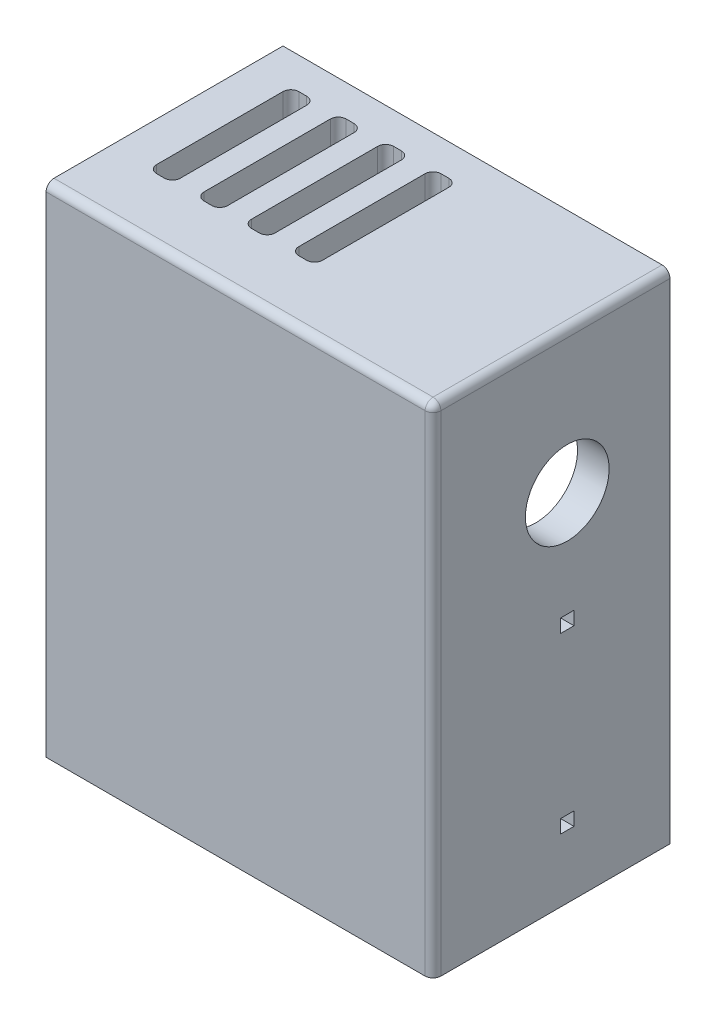
from build123d import *

# Parameters (mm, degrees)
SKETCH_1_W          = 49
SKETCH_1_H          = 63
EXTRUDE_1_DEPTH     = 4
SKETCH_2_W          = 45
SKETCH_2_H          = 4
SKETCH_2_W_2        = 4
SKETCH_2_H_2        = 59
EXTRUDE_2_DEPTH     = 26
SKETCH_3_W          = 14
SKETCH_3_H          = 8
SKETCH_3_W_2        = 30
EXTRUDE_3_DEPTH     = 7.2
SKETCH_5_R          = 5.3
CUT_EXTRUDE_1_DEPTH = 4
SKETCH_7_W          = 1.7
SKETCH_7_H          = 1.7
CUT_EXTRUDE_3_DEPTH = 6
SKETCH_8_W          = 1.7
SKETCH_8_H          = 1.7
CUT_EXTRUDE_4_DEPTH = 6
SKETCH_9_W          = 1.7
SKETCH_9_H          = 1.7
CUT_EXTRUDE_5_DEPTH = 6
FILLET_1_R          = 1
SKETCH_6_W          = 1.7
SKETCH_6_H          = 1.7
CUT_EXTRUDE_7_DEPTH = 5
SKETCH_10_W         = 15
SKETCH_10_H         = 27.7
EXTRUDE_4_DEPTH     = 2
CUT_EXTRUDE_8_DEPTH = 13
SKETCH_12_W         = 1.7
SKETCH_12_H         = 1.7
CUT_EXTRUDE_9_DEPTH = 5


with BuildPart() as part:
    # Эскиз1 → Бобышка-Вытянуть1 (new body)
    with BuildSketch(Plane.XY):
        with Locations((2.204545455, -4.295454545)):
            Rectangle(SKETCH_1_W, SKETCH_1_H)
    extrude(amount=EXTRUDE_1_DEPTH)

    # Эскиз2 → Бобышка-Вытянуть2 (add)
    with BuildSketch(Plane(origin=(0, 0, 0), x_dir=(-1, 0, 0), z_dir=(0, 0, -1))):
        with Locations((-0.204545455, 25.204545455)):
            Rectangle(SKETCH_2_W, SKETCH_2_H)
        with Locations((-24.704545455, -6.295454545)):
            Rectangle(SKETCH_2_W_2, SKETCH_2_H_2)
        with Locations((-24.704545455, 25.204545455)):
            Rectangle(SKETCH_2_W_2, SKETCH_2_H)
    extrude(amount=EXTRUDE_2_DEPTH)

    # Эскиз3 → Бобышка-Вытянуть3 (add)
    with BuildSketch(Plane(origin=(0, 0, 0), x_dir=(-1, 0, 0), z_dir=(0, 0, -1))):
        with Locations((-15.704545455, 19.204545455)):
            Rectangle(SKETCH_3_W, SKETCH_3_H)
        with Locations((-7.704545455, -23.795454545)):
            Rectangle(SKETCH_3_W_2, SKETCH_3_H)
    extrude(amount=EXTRUDE_3_DEPTH)

    # Эскиз5 → Вырез-Вытянуть1 (cut)
    with BuildSketch(Plane.ZY.offset(-22.704545455)):
        with Locations((-13, 9.204545455)):
            Circle(SKETCH_5_R)
    extrude(amount=-CUT_EXTRUDE_1_DEPTH, mode=Mode.SUBTRACT)

    # Эскиз7 → Вырез-Вытянуть3 (cut)
    with BuildSketch(Plane.ZY.offset(22.295454545)):
        with Locations((1.75, 24.954545455)):
            Rectangle(SKETCH_7_W, SKETCH_7_H)
    extrude(amount=-CUT_EXTRUDE_3_DEPTH, mode=Mode.SUBTRACT)

    # Эскиз8 → Вырез-Вытянуть4 (cut)
    with BuildSketch(Plane.XZ.offset(35.795454545)):
        with Locations((24.454545455, 1.75)):
            Rectangle(SKETCH_8_W, SKETCH_8_H)
    extrude(amount=-CUT_EXTRUDE_4_DEPTH, mode=Mode.SUBTRACT)

    # Эскиз9 → Вырез-Вытянуть5 (cut)
    with BuildSketch(Plane(origin=(0, 0, -26), x_dir=(-1, 0, 0), z_dir=(0, 0, -1))):
        with Locations((-24.454545455, 24.954545455)):
            Rectangle(SKETCH_9_W, SKETCH_9_H)
    extrude(amount=-CUT_EXTRUDE_5_DEPTH, mode=Mode.SUBTRACT)

    # Скругление1
    fillet_1_edges = [part.edges().sort_by_distance(p)[0] for p in [
        (26.704545455, -4.295454545, 4),
        (2.204545455, 27.204545455, 4),
        (26.704545455, 27.204545455, -11),
    ]]
    fillet(fillet_1_edges, radius=FILLET_1_R)

    # Эскиз6 → Вырез-Вытянуть7 (cut)
    with BuildSketch(Plane(origin=(26.704545455, 0, 0), x_dir=(0, 0, -1), z_dir=(1, 0, 0))):
        with Locations((13, -4.945454545)):
            Rectangle(SKETCH_6_W, SKETCH_6_H)
        with Locations((13, -26.945454545)):
            Rectangle(SKETCH_6_W, SKETCH_6_H)
    extrude(amount=-CUT_EXTRUDE_7_DEPTH, mode=Mode.SUBTRACT)

    # Эскиз10 → Бобышка-Вытянуть4 (add)
    with BuildSketch(Plane.ZY.offset(-22.704545455)):
        with Locations((-7.5, -15.945454545)):
            Rectangle(SKETCH_10_W, SKETCH_10_H)
    extrude(amount=EXTRUDE_4_DEPTH)

    # Эскиз11 → Вырез-Вытянуть8 (cut)
    with BuildSketch(Plane(origin=(0, 27.204545455, 0), x_dir=(1, 0, 0), z_dir=(0, 1, 0))):
        with BuildLine():
            Line((2.704545455, 4), (1.704545455, 4))
            ThreePointArc((1.704545455, 4), (0.997438673, 4.292893219), (0.704545455, 5))
            Line((0.704545455, 5), (0.704545455, 21))
            ThreePointArc((0.704545455, 21), (0.997438673, 21.707106781), (1.704545455, 22))
            Line((1.704545455, 22), (2.704545455, 22))
            ThreePointArc((2.704545455, 22), (3.411652236, 21.707106781), (3.704545455, 21))
            Line((3.704545455, 21), (3.704545455, 5))
            ThreePointArc((3.704545455, 5), (3.411652236, 4.292893219), (2.704545455, 4))
        make_face()
        with BuildLine():
            Line((-3.295454545, 4), (-4.295454545, 4))
            ThreePointArc((-4.295454545, 4), (-5.002561327, 4.292893219), (-5.295454545, 5))
            Line((-5.295454545, 5), (-5.295454545, 21))
            ThreePointArc((-5.295454545, 21), (-5.002561327, 21.707106781), (-4.295454545, 22))
            Line((-4.295454545, 22), (-3.295454545, 22))
            ThreePointArc((-3.295454545, 22), (-2.588347764, 21.707106781), (-2.295454545, 21))
            Line((-2.295454545, 21), (-2.295454545, 5))
            ThreePointArc((-2.295454545, 5), (-2.588347764, 4.292893219), (-3.295454545, 4))
        make_face()
        with BuildLine():
            Line((-9.295454545, 4), (-10.295454545, 4))
            ThreePointArc((-10.295454545, 4), (-11.002561327, 4.292893219), (-11.295454545, 5))
            Line((-11.295454545, 5), (-11.295454545, 21))
            ThreePointArc((-11.295454545, 21), (-11.002561327, 21.707106781), (-10.295454545, 22))
            Line((-10.295454545, 22), (-9.295454545, 22))
            ThreePointArc((-9.295454545, 22), (-8.588347764, 21.707106781), (-8.295454545, 21))
            Line((-8.295454545, 21), (-8.295454545, 5))
            ThreePointArc((-8.295454545, 5), (-8.588347764, 4.292893219), (-9.295454545, 4))
        make_face()
        with BuildLine():
            Line((-15.295454545, 4), (-16.295454545, 4))
            ThreePointArc((-16.295454545, 4), (-17.002561327, 4.292893219), (-17.295454545, 5))
            Line((-17.295454545, 5), (-17.295454545, 21))
            ThreePointArc((-17.295454545, 21), (-17.002561327, 21.707106781), (-16.295454545, 22))
            Line((-16.295454545, 22), (-15.295454545, 22))
            ThreePointArc((-15.295454545, 22), (-14.588347764, 21.707106781), (-14.295454545, 21))
            Line((-14.295454545, 21), (-14.295454545, 5))
            ThreePointArc((-14.295454545, 5), (-14.588347764, 4.292893219), (-15.295454545, 4))
        make_face()
    extrude(amount=-CUT_EXTRUDE_8_DEPTH, mode=Mode.SUBTRACT)

    # Эскиз12 → Вырез-Вытянуть9 (cut)
    with BuildSketch(Plane(origin=(0, 0, -7.2), x_dir=(-1, 0, 0), z_dir=(0, 0, -1))):
        with Locations((-13.654545455, 21.254545455)):
            Rectangle(SKETCH_12_W, SKETCH_12_H)
        with Locations((-13.654545455, -24.095454545)):
            Rectangle(SKETCH_12_W, SKETCH_12_H)
    extrude(amount=-CUT_EXTRUDE_9_DEPTH, mode=Mode.SUBTRACT)


solid = part.part
